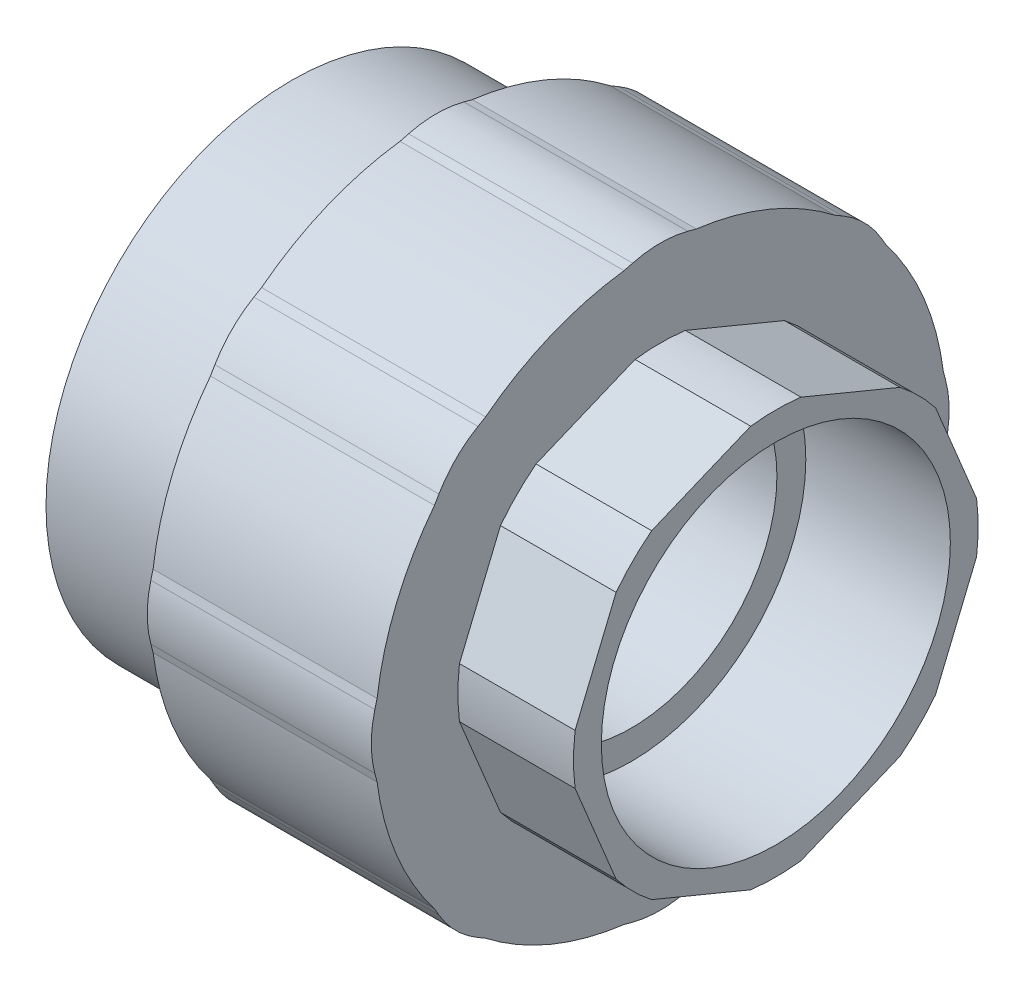
from build123d import *

# Parameters (mm, degrees)
SKETCH3_R           = 45.8838883
CUT_EXTRUDE1_DEPTH  = 16
BOSS_EXTRUDE1_DEPTH = 31
CIRPATTERN1_COUNT   = 8


with BuildPart() as part:
    # Sketch1 → Revolve1 (revolve)
    with BuildSketch(Plane.XY):
        Polygon((0, -25), (23.5, -25), (23.5, -20.15), (47, -20.15), (47, -24.15), (67, -24.15), (67, -28), (51, -28), (51, -39.5), (20, -39.5), (20, -34), (0, -34), align=None)
    revolve(axis=Axis((0, 0, 0), (1, 0, 0)))

    # Sketch3 → Cut-Extrude1 (cut)
    with BuildSketch(Plane(origin=(67, 0, 0), x_dir=(0, 0, -1), z_dir=(1, 0, 0))):
        Circle(SKETCH3_R)
        Polygon((0, 29.224589408), (-20.664905348, 20.664905348), (-29.224589408, 0), (-20.664905348, -20.664905348), (0, -29.224589408), (20.664905348, -20.664905348), (29.224589408, 0), (20.664905348, 20.664905348), align=None, mode=Mode.SUBTRACT)
    extrude(amount=-CUT_EXTRUDE1_DEPTH, mode=Mode.SUBTRACT)

    # Sketch4 → Boss-Extrude1 (add)
    with BuildSketch(Plane(origin=(51, 0, 0), x_dir=(0, 0, -1), z_dir=(1, 0, 0))):
        with BuildLine():
            Line((-3.822673778, 39.492546862), (-5, 39.182266397))
            Line((-5, 39.182266397), (5, 39.182266397))
            Line((5, 39.182266397), (3.822673778, 39.492546862))
            ThreePointArc((3.822673778, 39.492546862), (0, 39.987817799), (-3.822673778, 39.492546862))
        make_face()
    boss_extrude1 = extrude(amount=-BOSS_EXTRUDE1_DEPTH)

    # CirPattern1: Boss-Extrude1 ×8 about axis
    cirpattern1_axis = Axis((0, 0, 0), (1, 0, 0))
    for i in range(1, CIRPATTERN1_COUNT):
        add(boss_extrude1.rotate(cirpattern1_axis, i * 360 / CIRPATTERN1_COUNT))


solid = part.part
